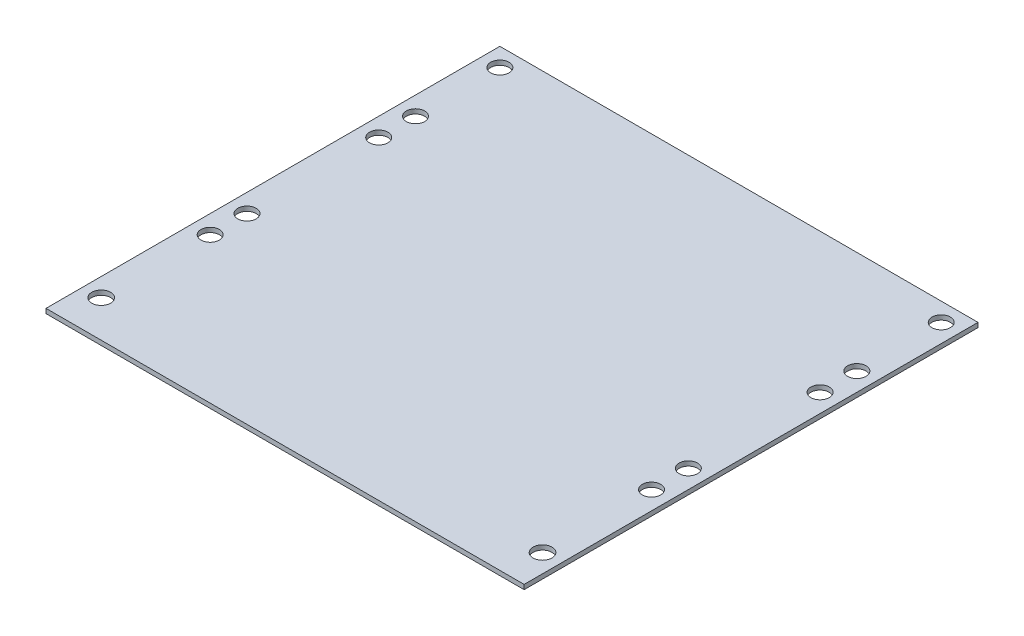
from build123d import *

# Parameters (mm, degrees)
SKETCH1_W           = 165.1
SKETCH1_H           = 156.718
SKETCH1_R           = 3.2639
SKETCH1_R_2         = 3.175
BOSS_EXTRUDE1_DEPTH = 1.5875


with BuildPart() as part:
    # Sketch1 → Boss-Extrude1 (new body)
    with BuildSketch(Plane(origin=(0, 0, 0), x_dir=(1, 0, 0), z_dir=(0, 1, 0))):
        with Locations((82.55, 78.359)):
            Rectangle(SKETCH1_W, SKETCH1_H)
        with Locations((6.35, 12.7)):
            Circle(SKETCH1_R, mode=Mode.SUBTRACT)
        with Locations((6.35, 150.368)):
            Circle(SKETCH1_R_2, mode=Mode.SUBTRACT)
        with Locations((158.75, 12.7)):
            Circle(SKETCH1_R, mode=Mode.SUBTRACT)
        with Locations((158.75, 150.368)):
            Circle(SKETCH1_R_2, mode=Mode.SUBTRACT)
        with Locations((6.35, 121.236556701)):
            Circle(SKETCH1_R_2, mode=Mode.SUBTRACT)
        with Locations((6.35, 108.536556701)):
            Circle(SKETCH1_R_2, mode=Mode.SUBTRACT)
        with Locations((6.35, 63.04698969)):
            Circle(SKETCH1_R_2, mode=Mode.SUBTRACT)
        with Locations((6.35, 50.34698969)):
            Circle(SKETCH1_R_2, mode=Mode.SUBTRACT)
        with Locations((158.75, 50.34698969)):
            Circle(SKETCH1_R_2, mode=Mode.SUBTRACT)
        with Locations((158.75, 63.04698969)):
            Circle(SKETCH1_R_2, mode=Mode.SUBTRACT)
        with Locations((158.75, 108.536556701)):
            Circle(SKETCH1_R_2, mode=Mode.SUBTRACT)
        with Locations((158.75, 121.236556701)):
            Circle(SKETCH1_R_2, mode=Mode.SUBTRACT)
    extrude(amount=BOSS_EXTRUDE1_DEPTH)


solid = part.part
